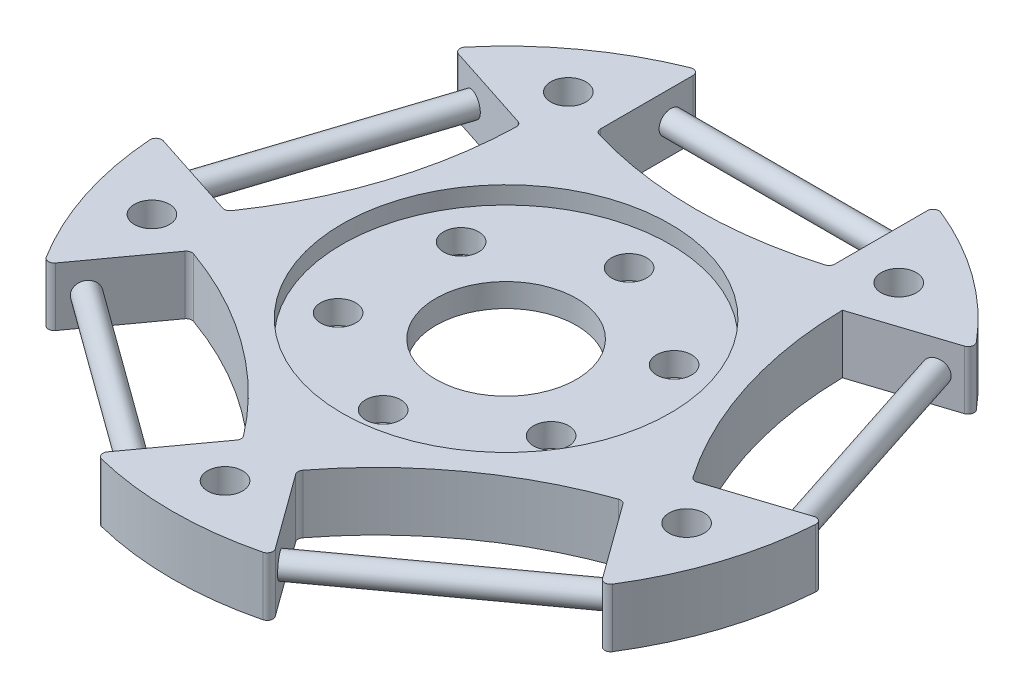
from build123d import *

# Parameters (mm, degrees)
SKETCH1_R           = 28.5
BOSS_EXTRUDE1_DEPTH = 5
CUT_EXTRUDE1_DEPTH  = 6
CIRPATTERN1_COUNT   = 5
SKETCH3_R           = 14
CUT_EXTRUDE2_DEPTH  = 1.5
SKETCH4_R           = 1.5
SKETCH4_R_2         = 6
CUT_EXTRUDE3_DEPTH  = 4.5
SKETCH5_R           = 1.5
CUT_EXTRUDE4_DEPTH  = 6
CIRPATTERN2_COUNT   = 5
FILLET1_R           = 0.5
SKETCH7_R           = 1
BOSS_EXTRUDE2_DEPTH = 20
CIRPATTERN3_COUNT   = 5


with BuildPart() as part:
    # Sketch1 → Boss-Extrude1 (new body)
    with BuildSketch(Plane(origin=(0, 0, 0), x_dir=(1, 0, 0), z_dir=(0, 1, 0))):
        Circle(SKETCH1_R)
    extrude(amount=BOSS_EXTRUDE1_DEPTH)

    # Sketch2 → Cut-Extrude1 (cut, through all)
    with BuildSketch(Plane(origin=(0, 5, 0), x_dir=(1, 0, 0), z_dir=(0, 1, 0))):
        with BuildLine():
            Line((10, 26.68801229), (10, 17.68801229))
            ThreePointArc((10, 17.68801229), (0, 16.180315356), (-10, 17.68801229))
            Line((-10, 17.68801229), (-10, 26.68801229))
            ThreePointArc((-10, 26.68801229), (0, 28.5), (10, 26.68801229))
        make_face()
    cut_extrude1 = extrude(amount=-CUT_EXTRUDE1_DEPTH, mode=Mode.SUBTRACT)

    # CirPattern1: Cut-Extrude1 ×5 about axis
    cirpattern1_axis = Axis((0, 0, 0), (0, 1, 0))
    for i in range(1, CIRPATTERN1_COUNT):
        add(cut_extrude1.rotate(cirpattern1_axis, i * 360 / CIRPATTERN1_COUNT), mode=Mode.SUBTRACT)

    # Sketch3 → Cut-Extrude2 (cut)
    with BuildSketch(Plane(origin=(0, 5, 0), x_dir=(1, 0, 0), z_dir=(0, 1, 0))):
        Circle(SKETCH3_R)
    cut_extrude2 = extrude(amount=-CUT_EXTRUDE2_DEPTH, mode=Mode.SUBTRACT)

    # Mirror1: Cut-Extrude2 across plane
    add(cut_extrude2.mirror(Plane.ZX.offset(2.5)), mode=Mode.SUBTRACT)

    # Sketch4 → Cut-Extrude3 (cut, through all)
    with BuildSketch(Plane(origin=(0, 3.5, 0), x_dir=(1, 0, 0), z_dir=(0, 1, 0))):
        with Locations((0, 10.5)):
            Circle(SKETCH4_R)
        with Locations((9.09326674, 5.25)):
            Circle(SKETCH4_R)
        with Locations((9.09326674, -5.25)):
            Circle(SKETCH4_R)
        with Locations((0, -10.5)):
            Circle(SKETCH4_R)
        with Locations((-9.09326674, -5.25)):
            Circle(SKETCH4_R)
        with Locations((-9.09326674, 5.25)):
            Circle(SKETCH4_R)
        Circle(SKETCH4_R_2)
    extrude(amount=-CUT_EXTRUDE3_DEPTH, mode=Mode.SUBTRACT)

    # Sketch5 → Cut-Extrude4 (cut, through all)
    with BuildSketch(Plane(origin=(0, 5, 0), x_dir=(1, 0, 0), z_dir=(0, 1, 0))):
        with Locations((0, -24)):
            Circle(SKETCH5_R)
    cut_extrude4 = extrude(amount=-CUT_EXTRUDE4_DEPTH, mode=Mode.SUBTRACT)

    # CirPattern2: Cut-Extrude4 ×5 about axis
    cirpattern2_axis = Axis((0, 0, 0), (0, 1, 0))
    for i in range(1, CIRPATTERN2_COUNT):
        add(cut_extrude4.rotate(cirpattern2_axis, i * 360 / CIRPATTERN2_COUNT), mode=Mode.SUBTRACT)

    # Fillet1
    fillet1_edges = [part.edges().sort_by_distance(p)[0] for p in [
        (-10, 2.5, -26.68801229),
        (10, 2.5, -26.68801229),
        (10, 2.5, -17.68801229),
        (-10, 2.5, -17.68801229),
        (22.291638052, 2.5, -17.757614507),
        (28.471977939, 2.5, 1.263515819),
        (19.912469293, 2.5, 4.044668769),
        (23.776989981, 2.5, 15.713202966),
        (7.596650093, 2.5, 27.468908012),
        (2.306582823, 2.5, 20.187755062),
        (18.48692271, 2.5, 8.432050017),
        (-7.596650093, 2.5, 27.468908012),
        (-23.776989981, 2.5, 15.713202966),
        (-18.48692271, 2.5, 8.432050017),
        (-2.306582823, 2.5, 20.187755062),
        (-28.471977939, 2.5, 1.263515819),
        (-22.291638052, 2.5, -17.757614507),
        (-13.732129405, 2.5, -14.976461557),
        (-19.912469293, 2.5, 4.044668769),
    ]]
    fillet(fillet1_edges, radius=FILLET1_R)

    # Sketch7 → Boss-Extrude2 (add)
    with BuildSketch(Plane(origin=(-8.090169944, 0, -5.877852523), x_dir=(0.587785252, 0, -0.809016994), z_dir=(0.809016994, 0, 0.587785252))):
        with Locations((-24.059120617, 2.5)):
            Circle(SKETCH7_R)
    boss_extrude2 = extrude(amount=BOSS_EXTRUDE2_DEPTH)

    # CirPattern3: Boss-Extrude2 ×5 about axis
    cirpattern3_axis = Axis((0, 3.5, 0), (0, 1, 0))
    for i in range(1, CIRPATTERN3_COUNT):
        add(boss_extrude2.rotate(cirpattern3_axis, i * 360 / CIRPATTERN3_COUNT))


solid = part.part
